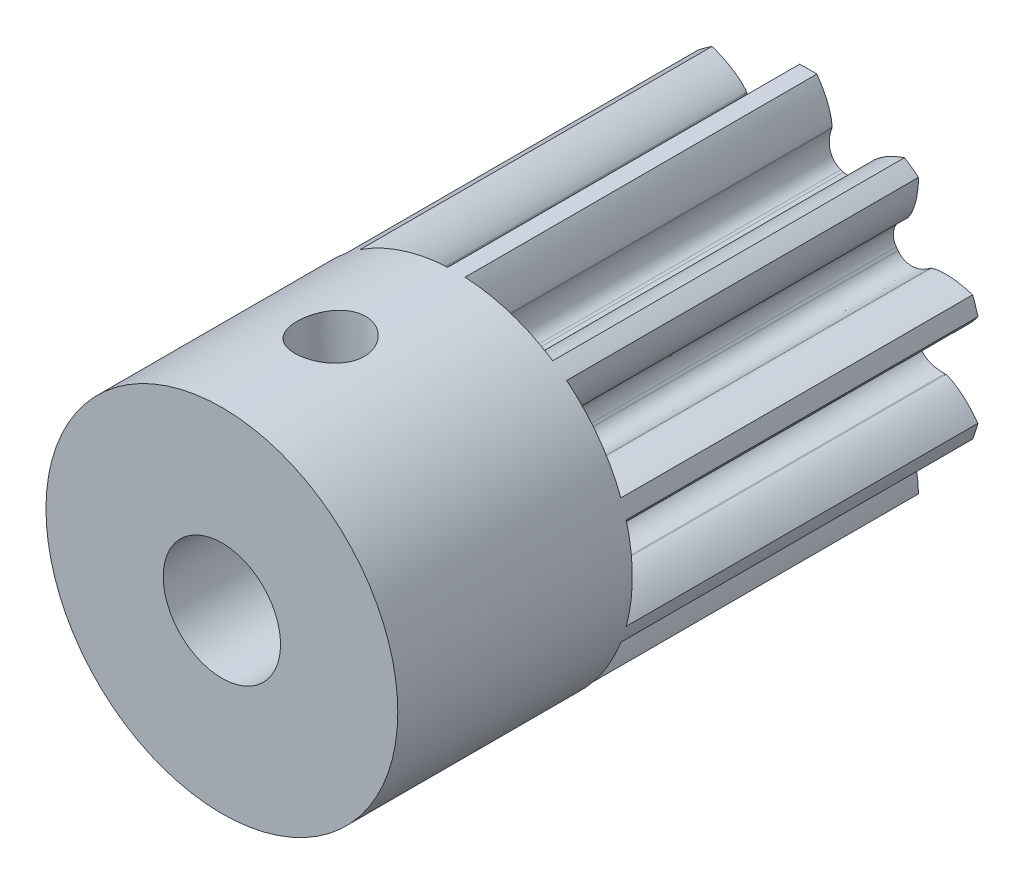
from build123d import *
from build123d.topology import SkipClean

# Parameters (mm, degrees)
TOOTH_START         = -1
TOOTH_DEPTH         = 6
TEETH_COUNT         = 10
ADDENDUM_DEPTH      = 7.650358403
ADDENDUM_DEPTH_BACK = 7.650358403
SKETCH6_OUTSIDE_W   = 10.17
SKETCH6_OUTSIDE_H   = 10.48
SKETCH6_OUTSIDE_R   = 3
SKETCH9_R           = 3
BOSS_EXTRUDE1_DEPTH = 4
SKETCH11_R          = 1
CUT_EXTRUDE1_DEPTH  = 11.862780638
SKETCH12_R          = 0.575
CUT_EXTRUDE2_DEPTH  = 12.263199085


with BuildPart() as part:
    # Sketch1 → Tooth (new body)
    with BuildSketch(Plane.XY.offset(TOOTH_START)):
        with BuildLine():
            Line((0.403833302, 2.337025202), (0.400760991, 2.320943747))
            add(Edge.make_bspline(
                [(0.400760991, 2.320943747), (0.386673551, 2.282139235), (0.370069341, 2.223430174), (0.359481749, 2.144320545), (0.357870732, 2.087044818), (0.363123959, 2.030301784), (0.376565354, 1.973817059), (0.40038547, 1.917902908), (0.451390546, 1.844336469), (0.51072073, 1.804476148), (0.556407001, 1.79054077)],
                knots=[0, 0, 0, 0, 0.20012551, 0.294348356, 0.386167986, 0.477231396, 0.569745357, 0.666449872, 0.770112617, 1, 1, 1, 1], degree=3))
            ThreePointArc((0.556407001, 1.79054077), (0, -1.875), (-0.556407001, 1.79054077))
            add(Edge.make_bspline(
                [(-0.400760991, 2.320943747), (-0.386673551, 2.282139235), (-0.370069341, 2.223430174), (-0.359481749, 2.144320545), (-0.357870732, 2.087044818), (-0.363123959, 2.030301784), (-0.376565354, 1.973817059), (-0.40038547, 1.917902908), (-0.451390546, 1.844336469), (-0.51072073, 1.804476148), (-0.556407001, 1.79054077)],
                knots=[0, 0, 0, 0, 0.20012551, 0.294348356, 0.386167986, 0.477231396, 0.569745357, 0.666449872, 0.770112617, 1, 1, 1, 1], degree=3))
            Line((-0.400760991, 2.320943747), (-0.403833302, 2.337025202))
            add(Edge.make_bspline(
                [(0, 3.177366371), (-0.067819183, 3.102854424), (-0.157523521, 2.989367158), (-0.252839345, 2.833104429), (-0.305563716, 2.729496796), (-0.344795573, 2.635088219), (-0.37229532, 2.551266676), (-0.389966802, 2.479197642), (-0.401521371, 2.409250483), (-0.404588452, 2.363118477), (-0.403833302, 2.337025202)],
                knots=[0, 0, 0, 0, 0.317753817, 0.454551878, 0.576630709, 0.683990311, 0.776630686, 0.854551835, 0.917753763, 1, 1, 1, 1], degree=3))
            add(Edge.make_bspline(
                [(0, 3.177366371), (0.067819183, 3.102854424), (0.157523521, 2.989367158), (0.252839345, 2.833104429), (0.305563716, 2.729496796), (0.344795573, 2.635088219), (0.37229532, 2.551266676), (0.389966802, 2.479197642), (0.401521371, 2.409250483), (0.404588452, 2.363118477), (0.403833302, 2.337025202)],
                knots=[0, 0, 0, 0, 0.317753817, 0.454551878, 0.576630709, 0.683990311, 0.776630686, 0.854551835, 0.917753763, 1, 1, 1, 1], degree=3))
        make_face()
    tooth = extrude(amount=TOOTH_DEPTH)

    # Teeth: Tooth ×10 about axis
    teeth_axis = Axis((0, 0, -1), (0, 0, 1))
    for i in range(1, TEETH_COUNT):
        add(tooth.rotate(teeth_axis, i * 360 / TEETH_COUNT))

    # Sketch6 outside → Addendum (cut, two sides: drawn at the far end of the back side and taken through both)
    with BuildSketch(Plane.XY.offset(-ADDENDUM_DEPTH_BACK)):
        Rectangle(SKETCH6_OUTSIDE_W, SKETCH6_OUTSIDE_H)
        Circle(SKETCH6_OUTSIDE_R, mode=Mode.SUBTRACT)
    extrude(amount=ADDENDUM_DEPTH + ADDENDUM_DEPTH_BACK, mode=Mode.SUBTRACT)

    # Sketch9 → Boss-Extrude1 (add)
    with BuildSketch(Plane.XY.offset(5)):
        with Locations(Location((0, 0, 0), (0, 0, 164.806178096))):
            Circle(SKETCH9_R)
    extrude(amount=BOSS_EXTRUDE1_DEPTH)

    # Sketch11 → Cut-Extrude1 (cut, through all)
    with BuildSketch(Plane(origin=(0, 0, -1), x_dir=(-1, 0, 0), z_dir=(0, 0, -1))):
        Circle(SKETCH11_R)
    extrude(amount=-CUT_EXTRUDE1_DEPTH, mode=Mode.SUBTRACT)

    # Sketch12 → Cut-Extrude2 (cut, through all)
    with SkipClean():  # the faces are left unmerged after this step: merging them gives an invalid solid
        with BuildSketch(Plane(origin=(0.146872407, -2.996402592, 0), x_dir=(-0.9988008641563334, -0.04895746889456052, 0), z_dir=(0.04895746889456052, -0.9988008641563334, 0))):
            with Locations(Location((0, -7, 0), (0, 0, 180))):
                Circle(SKETCH12_R)
        extrude(amount=-CUT_EXTRUDE2_DEPTH, mode=Mode.SUBTRACT)


solid = part.part
